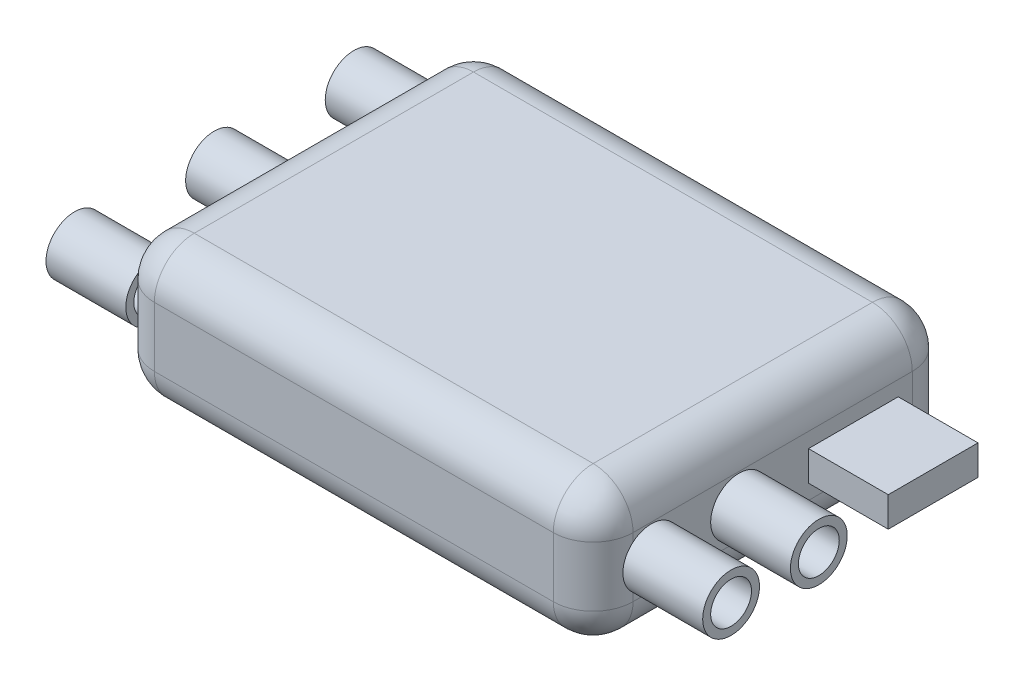
from build123d import *

# Parameters (mm, degrees)
BOSS_EXTRUDE1_DEPTH = 7
FILLET1_R           = 2
SKETCH2_R           = 1.434229719
SKETCH2_R_2         = 1.034229719
BOSS_EXTRUDE2_DEPTH = 4
SKETCH3_R           = 1.423607329
SKETCH3_R_2         = 1.023607329
SKETCH3_W           = 4.5
SKETCH3_H           = 1.5
BOSS_EXTRUDE3_DEPTH = 4


with BuildPart() as part:
    # Sketch1 → Boss-Extrude1 (new body)
    with BuildSketch(Plane(origin=(0, 0, 0), x_dir=(1, 0, 0), z_dir=(0, 1, 0))):
        with BuildLine():
            Line((-10, 9), (10, 9))
            ThreePointArc((10, 9), (11.414213562, 8.414213562), (12, 7))
            Line((12, 7), (12, -7))
            ThreePointArc((12, -7), (11.414213562, -8.414213562), (10, -9))
            Line((10, -9), (-10, -9))
            ThreePointArc((-10, -9), (-11.414213562, -8.414213562), (-12, -7))
            Line((-12, -7), (-12, 7))
            ThreePointArc((-12, 7), (-11.414213562, 8.414213562), (-10, 9))
        make_face()
    extrude(amount=BOSS_EXTRUDE1_DEPTH)

    # Fillet1
    fillet1_edges = [part.edges().sort_by_distance(p)[0] for p in [
        (0, 0, -9),
        (11.414213562, 0, -8.414213562),
        (12, 0, 0),
        (11.414213562, 0, 8.414213562),
        (11.414213562, 7, -8.414213562),
        (0, 7, -9),
        (-11.414213562, 7, -8.414213562),
        (-12, 7, 0),
        (-11.414213562, 7, 8.414213562),
        (0, 7, 9),
        (11.414213562, 7, 8.414213562),
        (0, 0, 9),
        (12, 7, 0),
        (-11.414213562, 0, 8.414213562),
        (-12, 0, 0),
        (-11.414213562, 0, -8.414213562),
    ]]
    fillet(fillet1_edges, radius=FILLET1_R)

    # Sketch2 → Boss-Extrude2 (add)
    with BuildSketch(Plane.ZY.offset(12)):
        with Locations((-7, 3.5)):
            Circle(SKETCH2_R)
        with Locations((-7, 3.5)):
            Circle(SKETCH2_R_2, mode=Mode.SUBTRACT)
        with Locations((0, 3.5)):
            Circle(SKETCH2_R)
        with Locations((0, 3.5)):
            Circle(SKETCH2_R_2, mode=Mode.SUBTRACT)
        with Locations((7, 3.5)):
            Circle(SKETCH2_R)
        with Locations((7, 3.5)):
            Circle(SKETCH2_R_2, mode=Mode.SUBTRACT)
    extrude(amount=BOSS_EXTRUDE2_DEPTH)

    # Sketch3 → Boss-Extrude3 (add)
    with BuildSketch(Plane(origin=(12, 0, 0), x_dir=(0, 0, -1), z_dir=(1, 0, 0))):
        with Locations((-6.085184826, 3.5)):
            Circle(SKETCH3_R)
        with Locations((-6.085184826, 3.5)):
            Circle(SKETCH3_R_2, mode=Mode.SUBTRACT)
        with Locations((-1.685184826, 3.5)):
            Circle(SKETCH3_R)
        with Locations((-1.685184826, 3.5)):
            Circle(SKETCH3_R_2, mode=Mode.SUBTRACT)
        with Locations((4.044962508, 3.5)):
            Rectangle(SKETCH3_W, SKETCH3_H)
    extrude(amount=BOSS_EXTRUDE3_DEPTH)


solid = part.part
